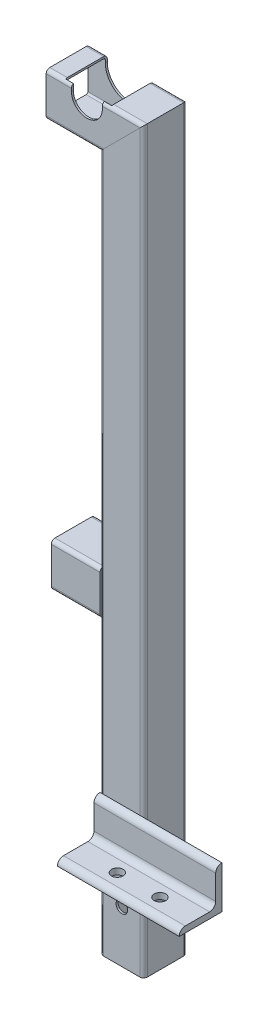
from build123d import *

# Parameters (mm, degrees)
STRUCTURAL_MEMBERMAIN_DEPTH        = 1
STRUCTURAL_MEMBERMAIN_DEPTH_BACK   = 80
STRUCTURAL_MEMBERMAIN_2_DEPTH      = 536.314422766
STRUCTURAL_MEMBERMAIN_3_DEPTH      = 88.414422766
STRUCTURAL_MEMBERMAIN_4_DEPTH      = 58.9
CUT_EXTRUDETOPRAILGUIDE_DEPTH      = 583.027129952
CUT_EXTRUDETOPRAILGUIDE_DEPTH_BACK = 583.027129952
STRUCTURAL_MEMBERANGLE_DEPTH       = 100
SKETCH15_R                         = 4.7625
CUT_EXTRUDEMOUNTINGHOLES_DEPTH     = 615.018452491
CUT_EXTRUDEENLARGERAILGUIDE_START  = -17.9
CUT_EXTRUDEENLARGERAILGUIDE_DEPTH  = 34.2
SKETCH17_R                         = 4.7625
CUT_EXTRUDE1_DEPTH                 = 613.782090143


with BuildPart() as part:
    # Sketch11 → Structural MemberMain (new, two sides)
    with BuildSketch(Plane(origin=(228.7, 0, 0), x_dir=(-1, 0, 0), z_dir=(0, 1, 0))) as structural_membermain_sk:
        with BuildLine():
            Line((-14.9, 17.9), (14.9, 17.9))
            ThreePointArc((14.9, 17.9), (17.021320344, 17.021320344), (17.9, 14.9))
            Line((17.9, 14.9), (17.9, -14.9))
            ThreePointArc((17.9, -14.9), (17.021320344, -17.021320344), (14.9, -17.9))
            Line((14.9, -17.9), (-14.9, -17.9))
            ThreePointArc((-14.9, -17.9), (-17.021320344, -17.021320344), (-17.9, -14.9))
            Line((-17.9, -14.9), (-17.9, 14.9))
            ThreePointArc((-17.9, 14.9), (-17.021320344, 17.021320344), (-14.9, 17.9))
        make_face()
        with BuildLine():
            Line((-14.9, 16.3), (14.9, 16.3))
            ThreePointArc((14.9, 16.3), (15.889949494, 15.889949494), (16.3, 14.9))
            Line((16.3, 14.9), (16.3, -14.9))
            ThreePointArc((16.3, -14.9), (15.889949494, -15.889949494), (14.9, -16.3))
            Line((14.9, -16.3), (-14.9, -16.3))
            ThreePointArc((-14.9, -16.3), (-15.889949494, -15.889949494), (-16.3, -14.9))
            Line((-16.3, -14.9), (-16.3, 14.9))
            ThreePointArc((-16.3, 14.9), (-15.889949494, 15.889949494), (-14.9, 16.3))
        make_face(mode=Mode.SUBTRACT)
    extrude(amount=STRUCTURAL_MEMBERMAIN_DEPTH)
    extrude(structural_membermain_sk.sketch, amount=-STRUCTURAL_MEMBERMAIN_DEPTH_BACK)

    # Structural MemberMain mitre 1
    split(bisect_by=Plane(origin=(228.7, 0, 0), x_dir=(1, 0, 0), z_dir=(0, -1, 0)), keep=Keep.TOP)

    # Sketch17 → Cut-Extrude1 (cut, through all)
    with BuildSketch(Plane.XY.offset(17.9)):
        with Locations((228.7, -37.5)):
            Circle(SKETCH17_R)
    extrude(amount=-CUT_EXTRUDE1_DEPTH, mode=Mode.SUBTRACT)


with BuildPart() as body_2:
    # Sketch11 on segment 2 (carried to segment 2) → Structural MemberMain 2 (new body)
    with BuildSketch(Plane(origin=(228.7, -1, 0), x_dir=(-1, 0, 0), z_dir=(0, 1, 0))):
        with BuildLine():
            Line((-14.9, 17.9), (14.9, 17.9))
            ThreePointArc((14.9, 17.9), (17.021320344, 17.021320344), (17.9, 14.9))
            Line((17.9, 14.9), (17.9, -14.9))
            ThreePointArc((17.9, -14.9), (17.021320344, -17.021320344), (14.9, -17.9))
            Line((14.9, -17.9), (-14.9, -17.9))
            ThreePointArc((-14.9, -17.9), (-17.021320344, -17.021320344), (-17.9, -14.9))
            Line((-17.9, -14.9), (-17.9, 14.9))
            ThreePointArc((-17.9, 14.9), (-17.021320344, 17.021320344), (-14.9, 17.9))
        make_face()
        with BuildLine():
            Line((-14.9, 16.3), (14.9, 16.3))
            ThreePointArc((14.9, 16.3), (15.889949494, 15.889949494), (16.3, 14.9))
            Line((16.3, 14.9), (16.3, -14.9))
            ThreePointArc((16.3, -14.9), (15.889949494, -15.889949494), (14.9, -16.3))
            Line((14.9, -16.3), (-14.9, -16.3))
            ThreePointArc((-14.9, -16.3), (-15.889949494, -15.889949494), (-16.3, -14.9))
            Line((-16.3, -14.9), (-16.3, 14.9))
            ThreePointArc((-16.3, 14.9), (-15.889949494, 15.889949494), (-14.9, 16.3))
        make_face(mode=Mode.SUBTRACT)
    extrude(amount=STRUCTURAL_MEMBERMAIN_2_DEPTH)

    # Structural MemberMain 2 mitre 1
    split(bisect_by=Plane(origin=(228.7, 0, 0), x_dir=(-1, 0, 0), z_dir=(0, 1, 0)), keep=Keep.TOP)

    # Structural MemberMain 2 mitre 2
    split(bisect_by=Plane(origin=(228.7, 509, 0), x_dir=(0.707106781, 0.707106781, 0), z_dir=(0.707106781, -0.707106781, 0)), keep=Keep.TOP)


with BuildPart() as body_3:
    # Sketch11 on segment 3 (carried to segment 3) → Structural MemberMain 3 (new body)
    with BuildSketch(Plane(origin=(255.014422766, 509, 0), x_dir=(0, -1, 0), z_dir=(-1, 0, 0))):
        with BuildLine():
            Line((-14.9, 17.9), (14.9, 17.9))
            ThreePointArc((14.9, 17.9), (17.021320344, 17.021320344), (17.9, 14.9))
            Line((17.9, 14.9), (17.9, -14.9))
            ThreePointArc((17.9, -14.9), (17.021320344, -17.021320344), (14.9, -17.9))
            Line((14.9, -17.9), (-14.9, -17.9))
            ThreePointArc((-14.9, -17.9), (-17.021320344, -17.021320344), (-17.9, -14.9))
            Line((-17.9, -14.9), (-17.9, 14.9))
            ThreePointArc((-17.9, 14.9), (-17.021320344, 17.021320344), (-14.9, 17.9))
        make_face()
        with BuildLine():
            Line((-14.9, 16.3), (14.9, 16.3))
            ThreePointArc((14.9, 16.3), (15.889949494, 15.889949494), (16.3, 14.9))
            Line((16.3, 14.9), (16.3, -14.9))
            ThreePointArc((16.3, -14.9), (15.889949494, -15.889949494), (14.9, -16.3))
            Line((14.9, -16.3), (-14.9, -16.3))
            ThreePointArc((-14.9, -16.3), (-15.889949494, -15.889949494), (-16.3, -14.9))
            Line((-16.3, -14.9), (-16.3, 14.9))
            ThreePointArc((-16.3, 14.9), (-15.889949494, 15.889949494), (-14.9, 16.3))
        make_face(mode=Mode.SUBTRACT)
    extrude(amount=STRUCTURAL_MEMBERMAIN_3_DEPTH)

    # Structural MemberMain 3 mitre 1
    split(bisect_by=Plane(origin=(228.7, 509, 0), x_dir=(-0.707106781, -0.707106781, 0), z_dir=(-0.707106781, 0.707106781, 0)), keep=Keep.TOP)

    # Sketch12 → Cut-ExtrudeTopRailGuide (cut, two sides)
    with BuildSketch(Plane.XY) as cut_extrudetoprailguide_sk:
        with BuildLine():
            Line((187.3, 521.7), (187.3, 532.1))
            ThreePointArc((187.3, 532.1), (200, 544.8), (212.7, 532.1))
            Line((212.7, 532.1), (212.7, 521.7))
            ThreePointArc((212.7, 521.7), (200, 509), (187.3, 521.7))
        make_face()
    extrude(amount=CUT_EXTRUDETOPRAILGUIDE_DEPTH, mode=Mode.SUBTRACT)
    extrude(cut_extrudetoprailguide_sk.sketch, amount=-CUT_EXTRUDETOPRAILGUIDE_DEPTH_BACK, mode=Mode.SUBTRACT)

    # Sketch16 → Cut-ExtrudeEnlargeRailGuide (cut)
    with BuildSketch(Plane.XY.offset(CUT_EXTRUDEENLARGERAILGUIDE_START)):
        with BuildLine():
            Line((219.05, 521.7), (219.05, 532.1))
            ThreePointArc((219.05, 532.1), (200, 551.15), (180.95, 532.1))
            Line((180.95, 532.1), (180.95, 521.7))
            ThreePointArc((180.95, 521.7), (200, 502.65), (219.05, 521.7))
        make_face()
    extrude(amount=CUT_EXTRUDEENLARGERAILGUIDE_DEPTH, mode=Mode.SUBTRACT)


with BuildPart() as body_4:
    # Sketch11 on segment 4 (carried to segment 4) → Structural MemberMain 4 (new body)
    with BuildSketch(Plane(origin=(170.8, 176.5, 0), x_dir=(0, 1, 0), z_dir=(1, 0, 0))):
        with BuildLine():
            Line((-14.9, 17.9), (14.9, 17.9))
            ThreePointArc((14.9, 17.9), (17.021320344, 17.021320344), (17.9, 14.9))
            Line((17.9, 14.9), (17.9, -14.9))
            ThreePointArc((17.9, -14.9), (17.021320344, -17.021320344), (14.9, -17.9))
            Line((14.9, -17.9), (-14.9, -17.9))
            ThreePointArc((-14.9, -17.9), (-17.021320344, -17.021320344), (-17.9, -14.9))
            Line((-17.9, -14.9), (-17.9, 14.9))
            ThreePointArc((-17.9, 14.9), (-17.021320344, 17.021320344), (-14.9, 17.9))
        make_face()
        with BuildLine():
            Line((-14.9, 16.3), (14.9, 16.3))
            ThreePointArc((14.9, 16.3), (15.889949494, 15.889949494), (16.3, 14.9))
            Line((16.3, 14.9), (16.3, -14.9))
            ThreePointArc((16.3, -14.9), (15.889949494, -15.889949494), (14.9, -16.3))
            Line((14.9, -16.3), (-14.9, -16.3))
            ThreePointArc((-14.9, -16.3), (-15.889949494, -15.889949494), (-16.3, -14.9))
            Line((-16.3, -14.9), (-16.3, 14.9))
            ThreePointArc((-16.3, 14.9), (-15.889949494, 15.889949494), (-14.9, 16.3))
        make_face(mode=Mode.SUBTRACT)
    extrude(amount=STRUCTURAL_MEMBERMAIN_4_DEPTH)

    # Structural MemberMain 4 mitre 1
    split(bisect_by=Plane(origin=(210.8, 176.5, 0), x_dir=(0, -1, 0), z_dir=(-1, 0, 0)), keep=Keep.TOP)


with BuildPart() as body_5:
    # Sketch14 → Structural MemberAngle (new body)
    with BuildSketch(Plane(origin=(210.8, 0, 17.9), x_dir=(0, 1, 0), z_dir=(1, 0, 0))):
        with BuildLine():
            Line((0, 0), (0, 35))
            ThreePointArc((0, 35), (3.535533906, 33.535533906), (5, 30))
            Line((5, 30), (5, 10))
            ThreePointArc((5, 10), (6.464466094, 6.464466094), (10, 5))
            Line((10, 5), (30, 5))
            ThreePointArc((30, 5), (33.535533906, 3.535533906), (35, 0))
            Line((35, 0), (0, 0))
        make_face()
    extrude(amount=STRUCTURAL_MEMBERANGLE_DEPTH)

    # Sketch15 → Cut-ExtrudeMountingHoles (cut, through all)
    with BuildSketch(Plane(origin=(0, 0, 0), x_dir=(1, 0, 0), z_dir=(0, 1, 0))):
        with Locations(Location((245, -37.9, 0), (0, 0, 90))):
            Circle(SKETCH15_R)
        with Locations(Location((280, -37.9, 0), (0, 0, 90))):
            Circle(SKETCH15_R)
    extrude(amount=CUT_EXTRUDEMOUNTINGHOLES_DEPTH, mode=Mode.SUBTRACT)


solid = Compound([part.part, body_2.part, body_3.part, body_4.part, body_5.part])
